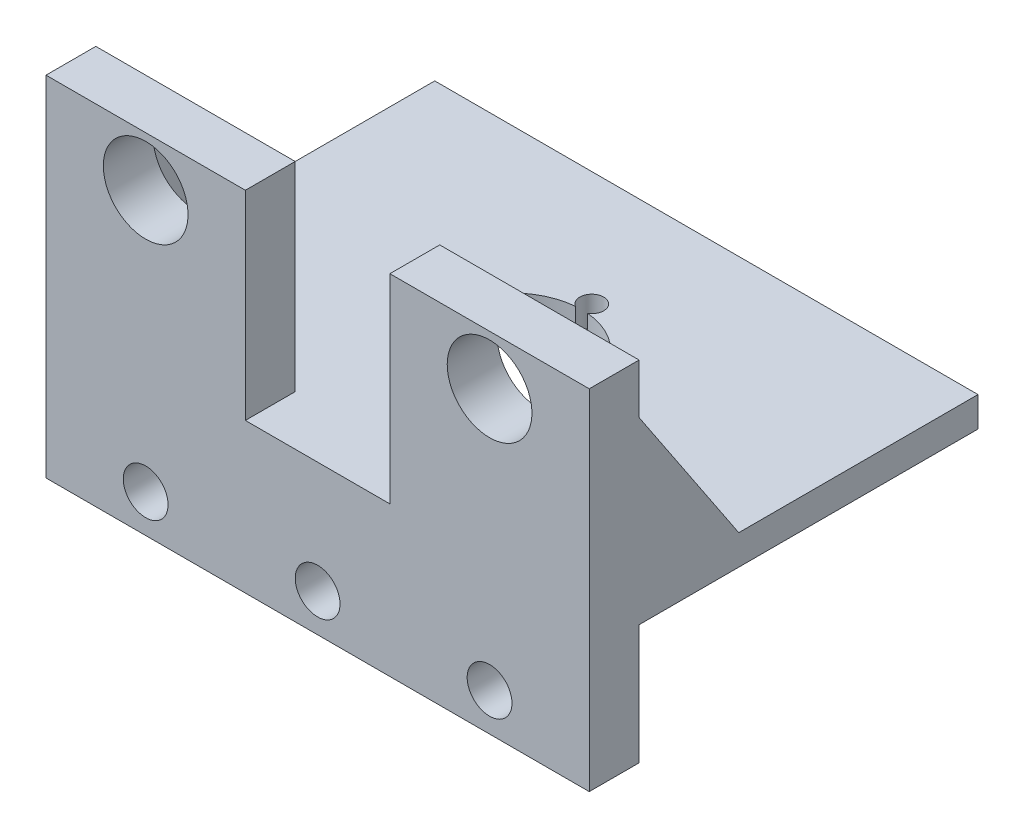
from build123d import *

# Parameters (mm, degrees)
SKETCH1_W                 = 54.5
SKETCH1_H                 = 39
BOSS_EXTRUDE1_DEPTH       = 3
SKETCH10_R                = 7
CUT_EXTRUDE1_DEPTH        = 5
M2_CLEARANCE_HOLE1_D      = 2.4
M2_CLEARANCE_HOLE1_DEPTH  = 17
M2_CLEARANCE_HOLE1_TIP    = 0.721032743
SKETCH12_W                = 20
SKETCH12_H                = 5
BOSS_EXTRUDE2_DEPTH       = 20
SKETCH13_R                = 4.25
CUT_EXTRUDE2_DEPTH        = 5
SKETCH16_W                = 54.5
SKETCH16_H                = 5
BOSS_EXTRUDE4_DEPTH       = 12
F_8_CLEARANCE_HOLE1_D     = 4.4958
F_8_CLEARANCE_HOLE1_DEPTH = 17
F_8_CLEARANCE_HOLE1_TIP   = 1.350674586
RIB2_REACH                = 67.289
SKETCH20_WALL_W           = 150.605379482
SKETCH20_WALL_H           = 5
RIB4_REACH                = 67.289
SKETCH21_WALL_W           = 150.605379482
SKETCH21_WALL_H           = 5


with BuildPart() as part:
    # Sketch1 → Boss-Extrude1 (new body)
    with BuildSketch(Plane(origin=(0, 0, 0), x_dir=(1, 0, 0), z_dir=(0, 1, 0))):
        with Locations((-13.399543841, 8.129312584)):
            Rectangle(SKETCH1_W, SKETCH1_H)
    extrude(amount=BOSS_EXTRUDE1_DEPTH)

    # Sketch10 → Cut-Extrude1 (cut)
    with BuildSketch(Plane(origin=(0, 3, 0), x_dir=(1, 0, 0), z_dir=(0, 1, 0))):
        with Locations(Location((-13.399543841, 8.129312584, 0), (0, 0, 270))):
            Circle(SKETCH10_R)
    extrude(amount=-CUT_EXTRUDE1_DEPTH, mode=Mode.SUBTRACT)

    # M2 Clearance Hole1
    with Locations(Plane(origin=(-13.399543841, 3, -0.129312584), x_dir=(0, 0, 1), z_dir=(0, 1, 0))):
        with Locations((0, 0), (-8, 7.99475453), (-8, -7.99475453), (-16, 0)):
            Hole(M2_CLEARANCE_HOLE1_D / 2, depth=M2_CLEARANCE_HOLE1_DEPTH)
            with Locations((0, 0, -(M2_CLEARANCE_HOLE1_DEPTH + M2_CLEARANCE_HOLE1_TIP / 2))):  # 118° drill point
                Cone(0, M2_CLEARANCE_HOLE1_D / 2, M2_CLEARANCE_HOLE1_TIP, mode=Mode.SUBTRACT)

    # Sketch12 → Boss-Extrude2 (add)
    with BuildSketch(Plane(origin=(0, 3, 0), x_dir=(1, 0, 0), z_dir=(0, 1, 0))):
        with Locations((3.850456159, -8.870687416)):
            Rectangle(SKETCH12_W, SKETCH12_H)
        with Locations((-30.649543841, -8.870687416)):
            Rectangle(SKETCH12_W, SKETCH12_H)
    extrude(amount=BOSS_EXTRUDE2_DEPTH)

    # Sketch13 → Cut-Extrude2 (cut)
    with BuildSketch(Plane(origin=(0, 0, 6.370687416), x_dir=(-1, 0, 0), z_dir=(0, 0, -1))):
        with Locations((-3.850456159, 18)):
            Circle(SKETCH13_R)
        with Locations((30.649543841, 18)):
            Circle(SKETCH13_R)
    extrude(amount=-CUT_EXTRUDE2_DEPTH, mode=Mode.SUBTRACT)

    # Sketch16 → Boss-Extrude4 (add)
    with BuildSketch(Plane.XZ):
        with Locations((-13.399543841, 8.870687416)):
            Rectangle(SKETCH16_W, SKETCH16_H)
    extrude(amount=BOSS_EXTRUDE4_DEPTH)

    # #8 Clearance Hole1
    with Locations(Plane(origin=(-30.649543841, -8.2, 11.370687416), x_dir=(1, 0, 0), z_dir=(0, 0, 1))):
        with Locations((0, 0), (17.25, 0), (34.5, 0)):
            Hole(F_8_CLEARANCE_HOLE1_D / 2, depth=F_8_CLEARANCE_HOLE1_DEPTH)
            with Locations((0, 0, -(F_8_CLEARANCE_HOLE1_DEPTH + F_8_CLEARANCE_HOLE1_TIP / 2))):  # 118° drill point
                Cone(0, F_8_CLEARANCE_HOLE1_D / 2, F_8_CLEARANCE_HOLE1_TIP, mode=Mode.SUBTRACT)

    # Sketch20 wall → Rib2 (add, up to next)
    with BuildSketch(Plane(origin=(13.850456159, 10.5, 1.370687416), x_dir=(0, -0.832050294338, -0.554700196225), z_dir=(0, 0.554700196225, -0.832050294338)), mode=Mode.PRIVATE) as rib2_sk1:
        with Locations((0, 2.5)):
            Rectangle(SKETCH20_WALL_W, SKETCH20_WALL_H)
    rib2_tool1 = extrude(rib2_sk1.sketch, amount=-RIB2_REACH, mode=Mode.PRIVATE) - part.part
    add(rib2_tool1.solids().sort_by_distance((13.850456159, 10.5, 1.370687416))[0])

    # Sketch21 wall → Rib4 (add, up to next)
    with BuildSketch(Plane(origin=(-40.649543841, 10.5, 1.370687416), x_dir=(0, -0.832050294338, -0.554700196225), z_dir=(0, -0.554700196225, 0.832050294338)), mode=Mode.PRIVATE) as rib4_sk1:
        with Locations((0, 2.5)):
            Rectangle(SKETCH21_WALL_W, SKETCH21_WALL_H)
    rib4_tool1 = extrude(rib4_sk1.sketch, amount=RIB4_REACH, mode=Mode.PRIVATE) - part.part
    add(rib4_tool1.solids().sort_by_distance((-40.649543841, 10.5, 1.370687416))[0])


solid = part.part
